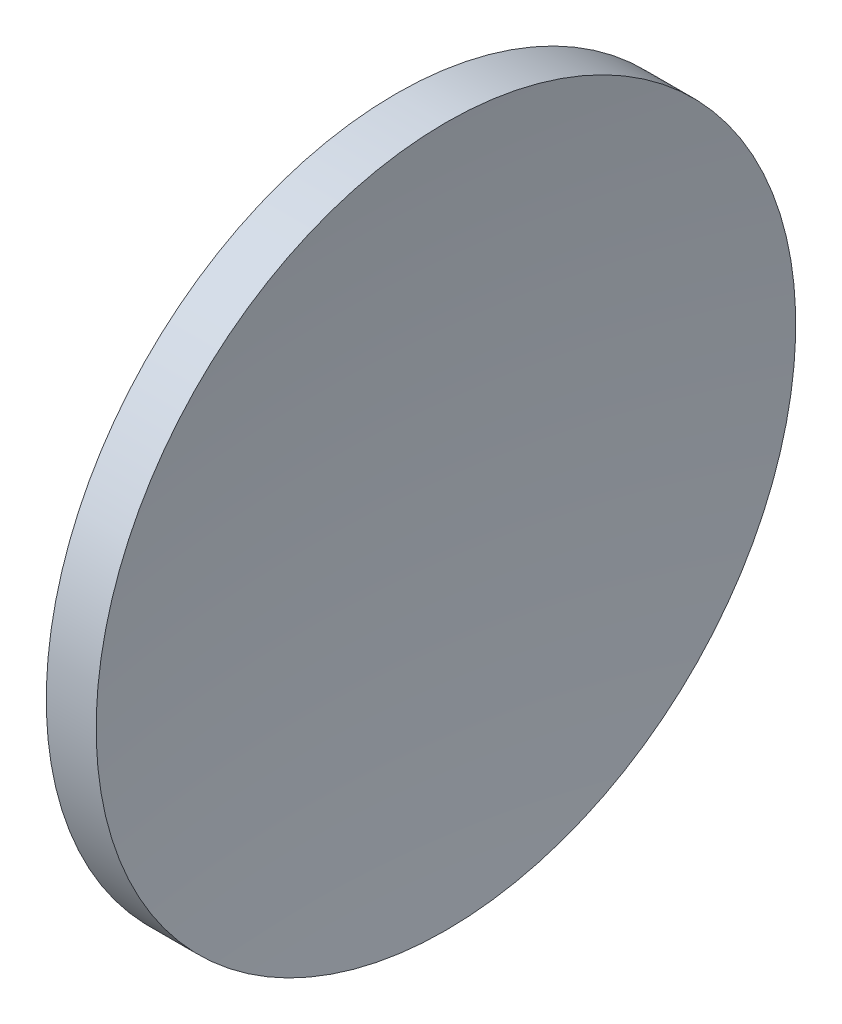
from build123d import *


with BuildPart() as part:
    # 草图1 → 旋转1 (revolve)
    with BuildSketch(Plane.XY):
        with BuildLine():
            Line((249.941417502, 155.433680942), (253.506454168, 155.433680942))
            ThreePointArc((253.506454168, 155.433680942), (252.288639547, 142.960037409), (251.882131121, 130.433680942))
            Line((251.882131121, 130.433680942), (245.282131121, 130.433680942))
            ThreePointArc((245.282131121, 130.433680942), (246.456895595, 143.148917369), (249.941417502, 155.433680942))
        make_face()
    revolve(axis=Axis((231.888982596, 130.433680942, 0), (1, 0, 0)))


solid = part.part
